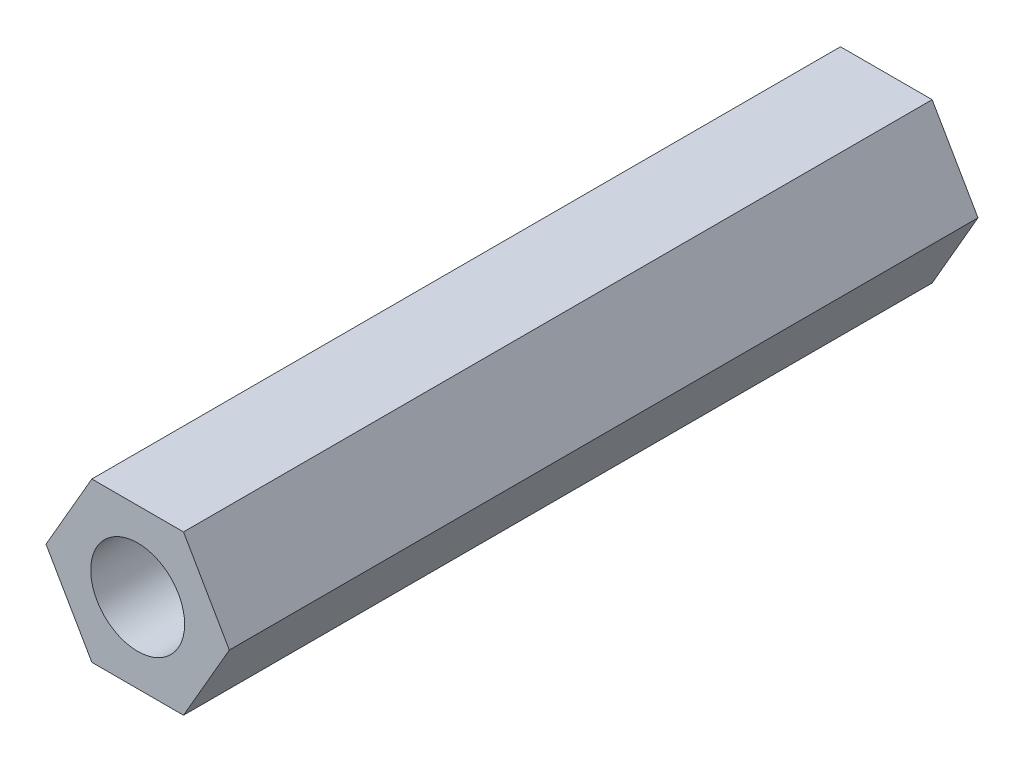
from build123d import *

# Parameters (mm, degrees)
SKETCH1_R           = 1.397
BOSS_EXTRUDE1_DEPTH = 22.2758


with BuildPart() as part:
    # Sketch1 → Boss-Extrude1 (new body)
    with BuildSketch(Plane.XY):
        Polygon((2.62285315, 106.888971188), (1.259036344, 104.526771188), (2.62285315, 102.164571188), (5.350486762, 102.164571188), (6.714303568, 104.526771188), (5.350486762, 106.888971188), align=None)
        with Locations((3.986669956, 104.526771188)):
            Circle(SKETCH1_R, mode=Mode.SUBTRACT)
    extrude(amount=BOSS_EXTRUDE1_DEPTH)


solid = part.part
